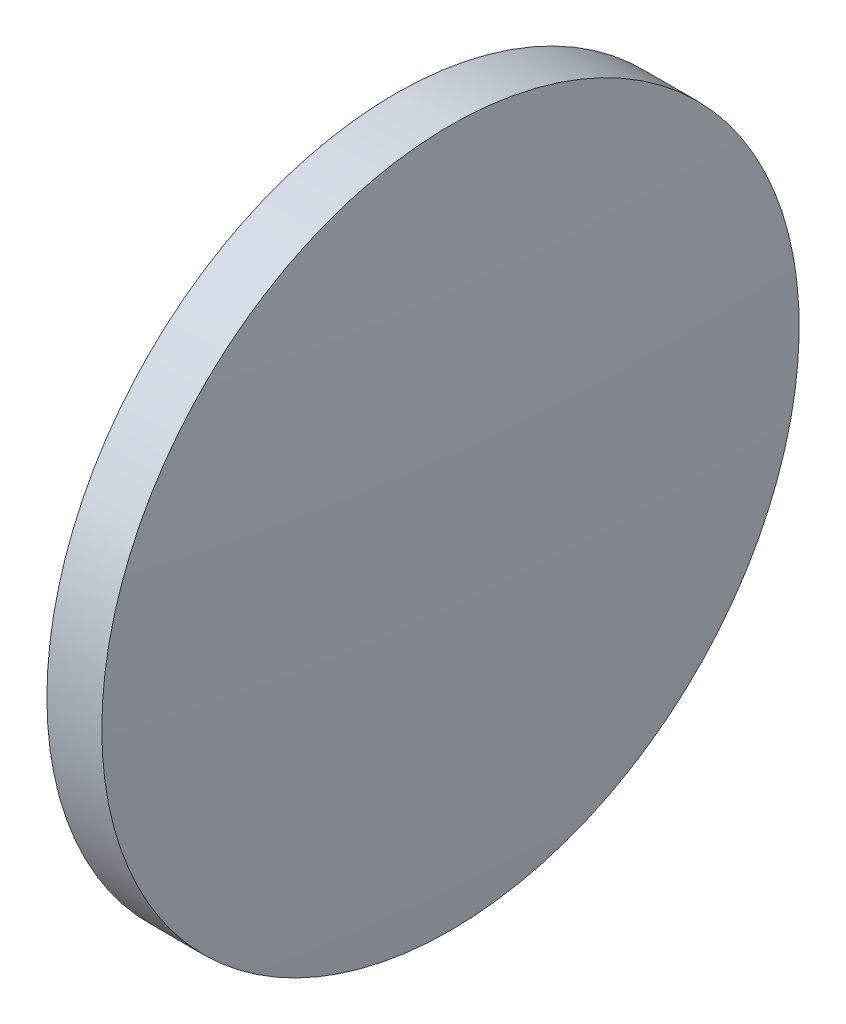
from build123d import *

# Parameters (mm, degrees)
SKETCH_1_ONE_SIDE_W = 1.999342857
SKETCH_1_ONE_SIDE_H = 12.7


with BuildPart() as part:
    # 草图1 one side → 旋转1 (revolve)
    with BuildSketch(Plane.XY, mode=Mode.PRIVATE) as revolve_1_sk:
        with Locations((86.458193775, 54.966113023)):
            Rectangle(SKETCH_1_ONE_SIDE_W, SKETCH_1_ONE_SIDE_H)
        with BuildLine():
            Line((85.008216632, 48.616113023), (85.458522346, 48.616113023))
            Line((85.458522346, 48.616113023), (85.458522346, 61.316113023))
            ThreePointArc((85.458522346, 61.316113023), (85.120828421, 54.970103408), (85.008216632, 48.616113023))
        make_face()
        with BuildLine():
            Line((87.457865203, 48.616113023), (87.908170918, 48.616113023))
            ThreePointArc((87.908170918, 48.616113023), (87.795559128, 54.970103408), (87.457865203, 61.316113023))
            Line((87.457865203, 61.316113023), (87.457865203, 48.616113023))
        make_face()
    revolve(revolve_1_sk.sketch.rotate(Axis((79.305401351, 48.616113023, 0), (1, 0, 0)), 90), axis=Axis((79.305401351, 48.616113023, 0), (1, 0, 0)))  # turned: the seam where the file's is


solid = part.part
